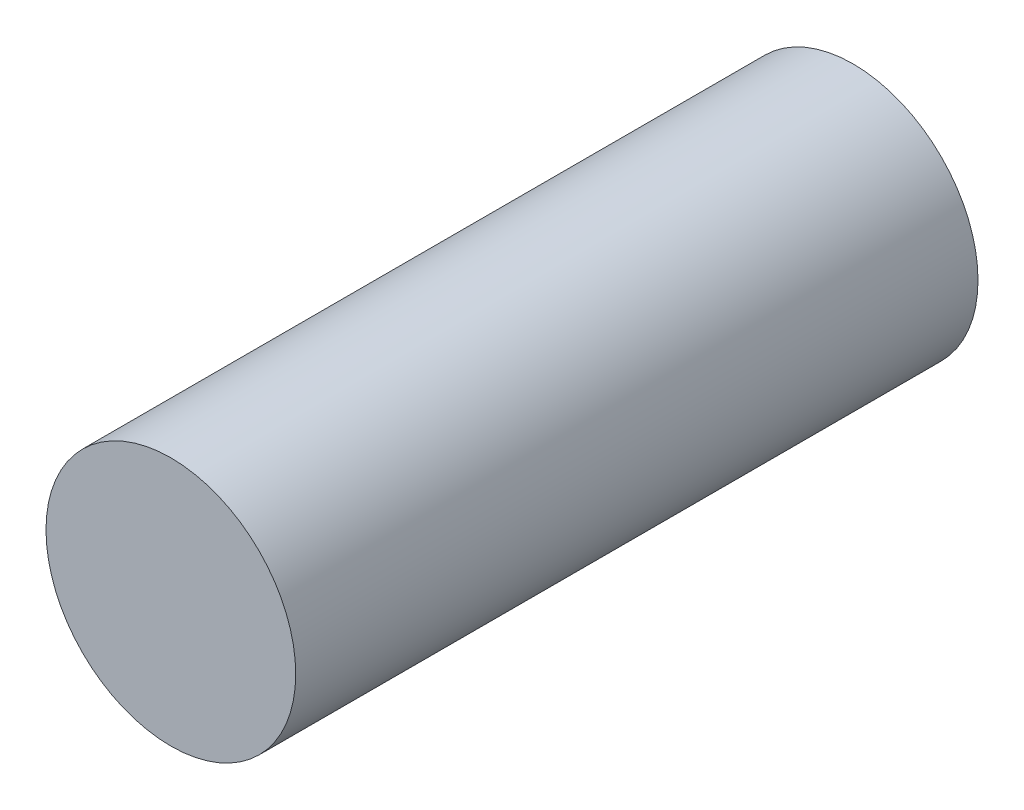
from build123d import *

# Parameters (mm, degrees)
SKETCH1_R           = 27.451016565
BOSS_EXTRUDE1_DEPTH = 150


with BuildPart() as part:
    # Sketch1 → Boss-Extrude1 (new body)
    with BuildSketch(Plane.XY):
        Circle(SKETCH1_R)
    extrude(amount=BOSS_EXTRUDE1_DEPTH)


solid = part.part
